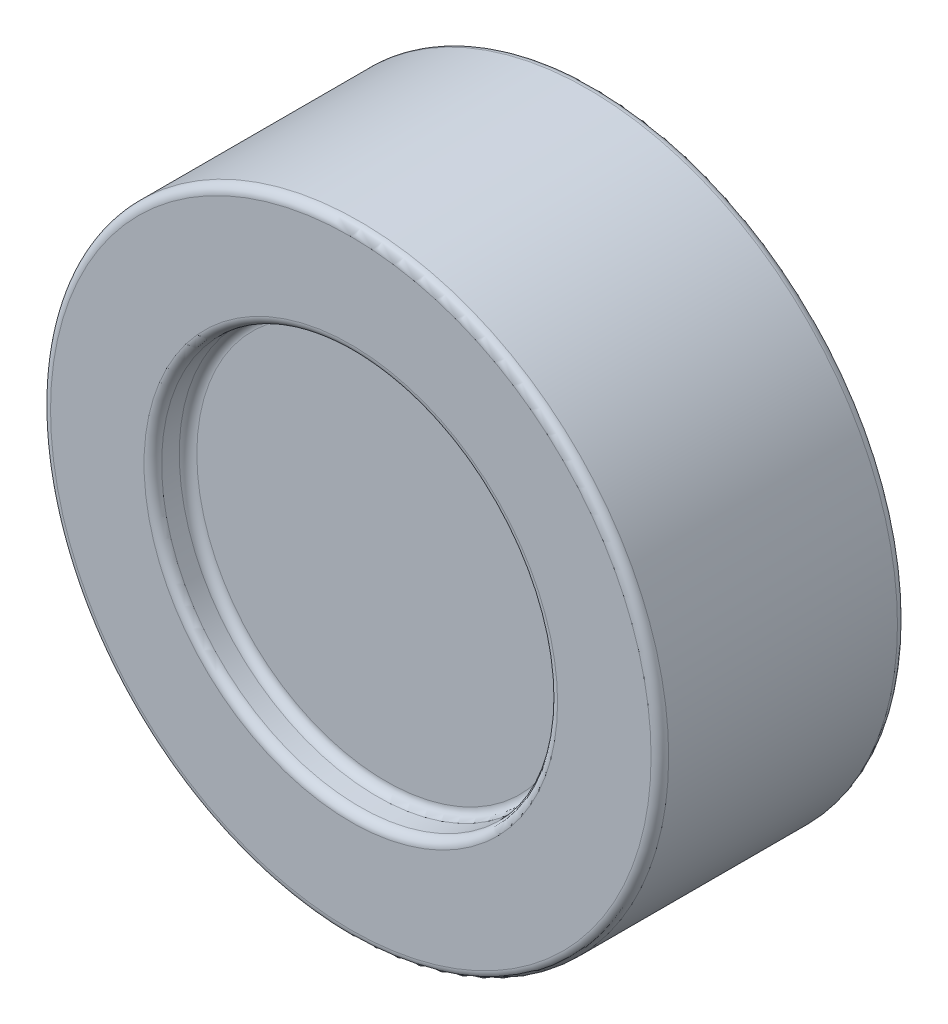
from build123d import *

# Parameters (mm, degrees)
ESQUISSE1_R        = 22.5
BOSS_EXTRU_1_DEPTH = 24
ESQUISSE1_4_R      = 35.125
ESQUISSE1_4_R_2    = 22.5
BOSS_EXTRU_2_DEPTH = 28
CONG_1_R           = 1


with BuildPart() as part:
    # Esquisse1 → Boss.-Extru.1 (new body)
    with BuildSketch(Plane.XY):
        Circle(ESQUISSE1_R)
    extrude(amount=BOSS_EXTRU_1_DEPTH)

    # Esquisse1_4 → Boss.-Extru.2 (add)
    with BuildSketch(Plane.XY):
        Circle(ESQUISSE1_4_R)
        Circle(ESQUISSE1_4_R_2, mode=Mode.SUBTRACT)
    extrude(amount=BOSS_EXTRU_2_DEPTH)

    # Congé1
    cong_1_edges = [part.edges().sort_by_distance(p)[0] for p in [
        (-22.5, 0, 28),
        (-22.5, 0, 24),
        (-35.125, 0, 0),
        (-35.125, 0, 28),
    ]]
    fillet(cong_1_edges, radius=CONG_1_R)


solid = part.part
